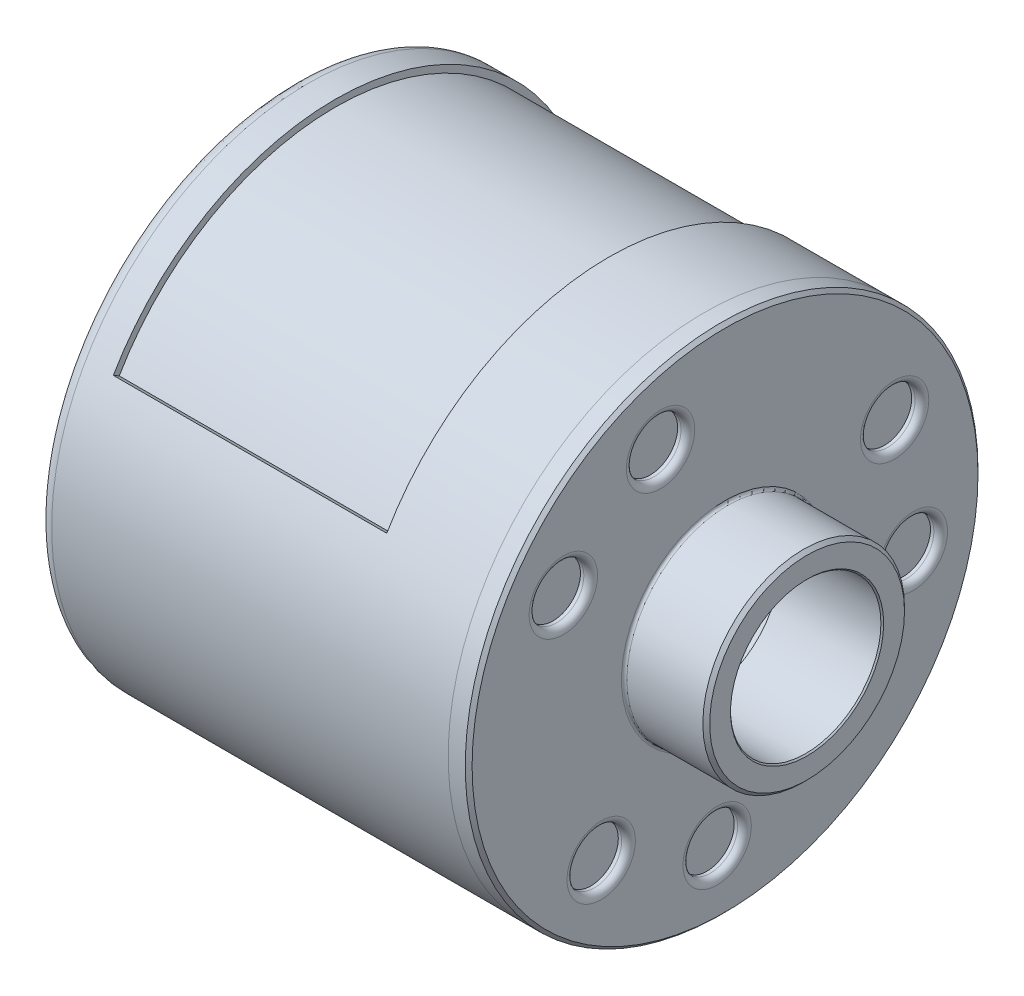
from build123d import *

# Parameters (mm, degrees)
SKETCH1_R           = 25
BOSS_EXTRUDE1_DEPTH = 40
SHELL1_T            = -2
SCALE9_SCALE        = 1.5
SKETCH2_R           = 37.5
BOSS_EXTRUDE2_DEPTH = 3
BOSS_EXTRUDE3_START = 3
SKETCH2_3_R         = 14.75
SKETCH2_3_R_2       = 11
BOSS_EXTRUDE3_DEPTH = 12
FILLET1_R           = 0.4
CHAMFER1_SIZE       = 0.5
CHAMFER2_SIZE       = 0.5
CHAMFER3_SIZE       = 0.2
FILLET2_R           = 2
SKETCH8_R           = 11
CUT_EXTRUDE2_DEPTH  = 10
SKETCH9_R           = 4
CUT_EXTRUDE3_DEPTH  = 1.5
FILLET3_R           = 1
FILLET4_R           = 1
FILLET5_R           = 1
CUT_EXTRUDE4_START  = -40
CUT_EXTRUDE4_DEPTH  = 40


with BuildPart() as part:
    # Sketch1 → Boss-Extrude1 (new body)
    with BuildSketch(Plane(origin=(0, 0, 0), x_dir=(0, 0, -1), z_dir=(1, 0, 0))):
        Circle(SKETCH1_R)
    extrude(amount=BOSS_EXTRUDE1_DEPTH)

    # Shell1
    shell1_openings = [part.faces().sort_by_distance(p)[0] for p in [
        (40, 0, 0),
    ]]
    offset(amount=SHELL1_T, openings=shell1_openings, kind=Kind.INTERSECTION)


with BuildPart() as part_1:
    # Scale9: scaled about (0, 0, 0)
    add(part.part.scale(SCALE9_SCALE))

    # Fillet2
    fillet2_edges = [part_1.edges().sort_by_distance(p)[0] for p in [
        (0, 0, 37.5),
    ]]
    fillet(fillet2_edges, radius=FILLET2_R)

    # Sketch11 → Cut-Extrude4 (cut)
    with BuildSketch(Plane(origin=(46, 0, 0), x_dir=(0, 0, -1), z_dir=(1, 0, 0)).offset(CUT_EXTRUDE4_START)):
        with BuildLine():
            Line((31.609927238, 18.25), (32.475952642, 18.75))
            ThreePointArc((32.475952642, 18.75), (0, 37.5), (-32.475952642, 18.75))
            Line((-32.475952642, 18.75), (-31.609927238, 18.25))
            ThreePointArc((-31.609927238, 18.25), (0, 36.5), (31.609927238, 18.25))
        make_face()
    extrude(amount=CUT_EXTRUDE4_DEPTH, mode=Mode.SUBTRACT)


with BuildPart() as body_2:
    # Sketch2 → Boss-Extrude2 (new body)
    with BuildSketch(Plane(origin=(60, 0, 0), x_dir=(0, 0, -1), z_dir=(1, 0, 0))):
        Circle(SKETCH2_R)
    extrude(amount=BOSS_EXTRUDE2_DEPTH)

    # Sketch2_3 → Boss-Extrude3 (add)
    with BuildSketch(Plane(origin=(60, 0, 0), x_dir=(0, 0, -1), z_dir=(1, 0, 0)).offset(BOSS_EXTRUDE3_START)):
        Circle(SKETCH2_3_R)
        Circle(SKETCH2_3_R_2, mode=Mode.SUBTRACT)
    extrude(amount=BOSS_EXTRUDE3_DEPTH)

    # Fillet1
    fillet1_edges = [body_2.edges().sort_by_distance(p)[0] for p in [
        (63, 0, 14.75),
    ]]
    fillet(fillet1_edges, radius=FILLET1_R)

    # Chamfer1
    chamfer1_edges = [body_2.edges().sort_by_distance(p)[0] for p in [
        (63, 0, 37.5),
    ]]
    chamfer(chamfer1_edges, length=CHAMFER1_SIZE)

    # Chamfer2
    chamfer2_edges = [body_2.edges().sort_by_distance(p)[0] for p in [
        (75, 0, 14.75),
    ]]
    chamfer(chamfer2_edges, length=CHAMFER2_SIZE)

    # Chamfer3
    chamfer3_edges = [body_2.edges().sort_by_distance(p)[0] for p in [
        (75, 0, 11),
    ]]
    chamfer(chamfer3_edges, length=CHAMFER3_SIZE)

    # Sketch8 → Cut-Extrude2 (cut)
    with BuildSketch(Plane(origin=(63, 0, 0), x_dir=(0, 0, -1), z_dir=(1, 0, 0))):
        Circle(SKETCH8_R)
    extrude(amount=-CUT_EXTRUDE2_DEPTH, mode=Mode.SUBTRACT)

    # Sketch9 → Cut-Extrude3 (cut)
    with BuildSketch(Plane(origin=(63, 0, 0), x_dir=(0, 0, -1), z_dir=(1, 0, 0))):
        with Locations((27.547933766, -5.01112215)):
            Circle(SKETCH9_R)
        with Locations((-18.113725967, -21.351649388)):
            Circle(SKETCH9_R)
        with Locations((-9.4342078, 26.362771539)):
            Circle(SKETCH9_R)
        with Locations((24.805020706, 12.98887785)):
            Circle(SKETCH9_R)
        with Locations((-1.153812168, -27.976216997)):
            Circle(SKETCH9_R)
        with Locations((-23.651208537, 14.987339148)):
            Circle(SKETCH9_R)
    extrude(amount=-CUT_EXTRUDE3_DEPTH, mode=Mode.SUBTRACT)

    # Fillet3
    fillet3_edges = [body_2.edges().sort_by_distance(p)[0] for p in [
        (63, -5.01112215, -23.547933766),
    ]]
    fillet(fillet3_edges, radius=FILLET3_R)

    # Fillet4
    fillet4_edges = [body_2.edges().sort_by_distance(p)[0] for p in [
        (63, -21.351649388, 22.113725967),
        (63, 26.362771539, 13.4342078),
    ]]
    fillet(fillet4_edges, radius=FILLET4_R)

    # Fillet5
    fillet5_edges = [body_2.edges().sort_by_distance(p)[0] for p in [
        (63, 14.987339148, 27.651208537),
        (63, -27.976216997, 5.153812168),
        (63, 12.98887785, -20.805020706),
    ]]
    fillet(fillet5_edges, radius=FILLET5_R)


solid = Compound([part_1.part, body_2.part])
